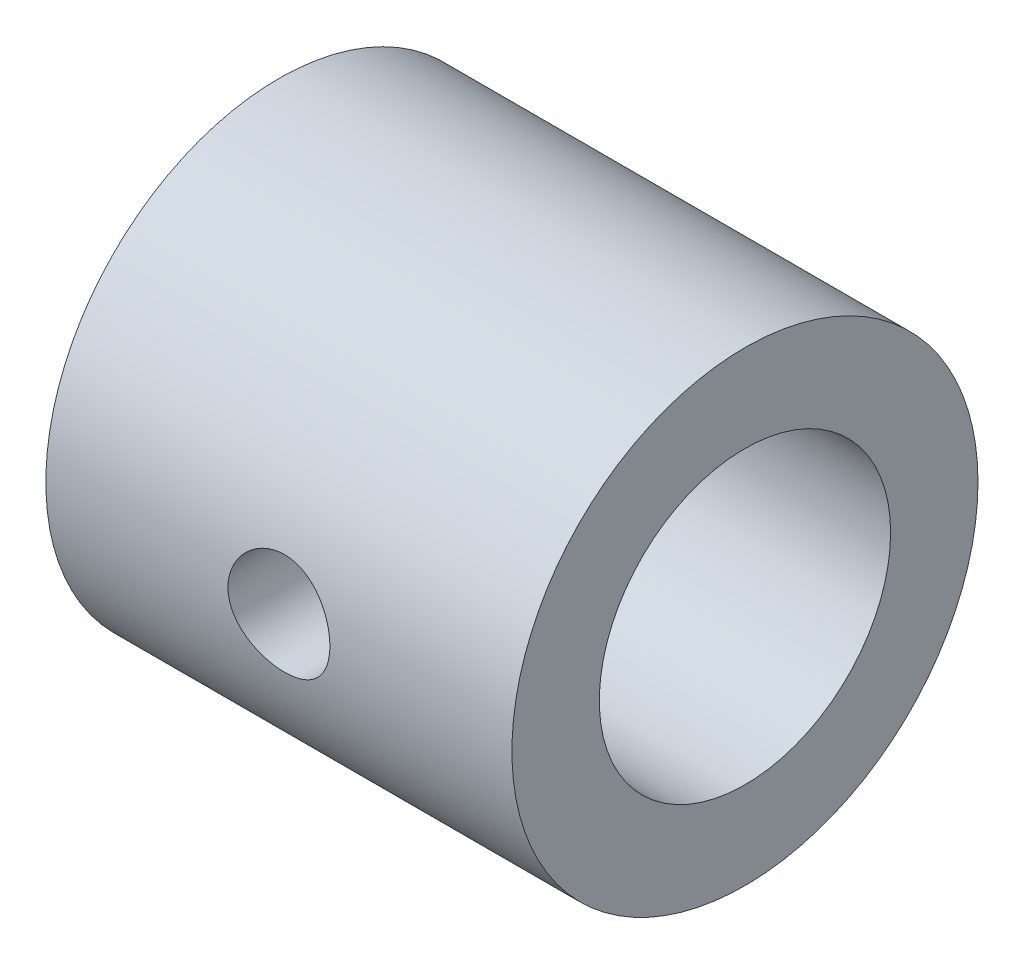
from build123d import *

# Parameters (mm, degrees)
SKETCH1_R           = 6.35
SKETCH1_R_2         = 3.96875
EXTRUDE1_DEPTH      = 6.35
EXTRUDE1_DEPTH_BACK = 6.35
CUT_EXTRUDE1_START  = -6.35
SKETCH2_R           = 1.3890625
CUT_EXTRUDE1_DEPTH  = 12.7


with BuildPart() as part:
    # Sketch1 → Extrude1 (new body, two sides)
    with BuildSketch(Plane(origin=(0, 0, 0), x_dir=(0, 0, -1), z_dir=(1, 0, 0))) as extrude1_sk:
        Circle(SKETCH1_R)
        Circle(SKETCH1_R_2, mode=Mode.SUBTRACT)
    extrude(amount=EXTRUDE1_DEPTH)
    extrude(extrude1_sk.sketch, amount=-EXTRUDE1_DEPTH_BACK)

    # Sketch2 → Cut-Extrude1 (cut)
    with BuildSketch(Plane.XY.offset(CUT_EXTRUDE1_START)):
        Circle(SKETCH2_R)
    extrude(amount=CUT_EXTRUDE1_DEPTH, mode=Mode.SUBTRACT)


solid = part.part
